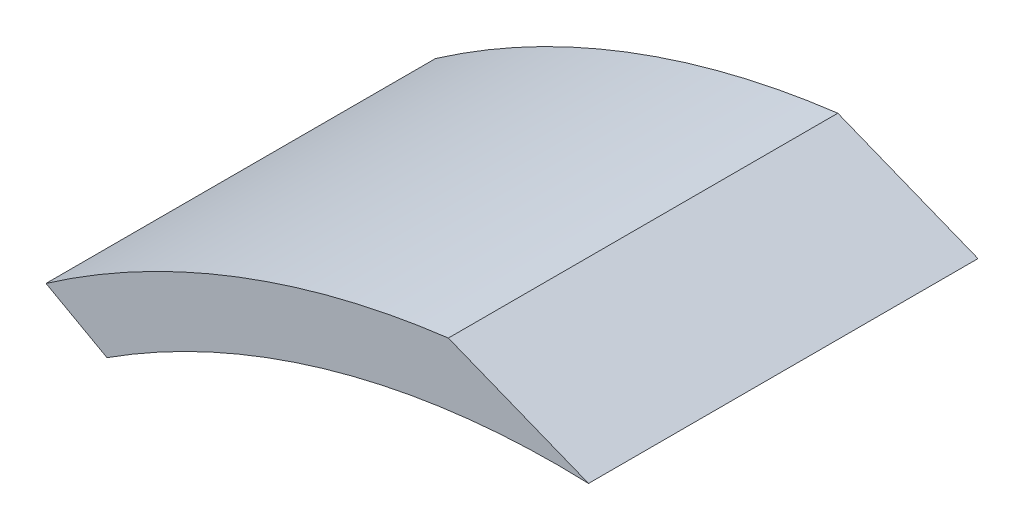
from build123d import *

# Parameters (mm, degrees)
BOSS_EXTRUDE1_DEPTH = 210
CUT_EXTRUDE1_REACH  = 379.535
CUT_EXTRUDE2_REACH  = 377.003


with BuildPart() as part:
    # Sketch1 → Boss-Extrude1 (new body)
    with BuildSketch(Plane.XY):
        with BuildLine():
            Line((0, 0), (0, -33.45))
            ThreePointArc((0, -33.45), (-142.866754092, -51.269235769), (-272.793704391, -113.296827807))
            Line((-272.793704391, -113.296827807), (-292.568960472, -86.318285465))
            ThreePointArc((-292.568960472, -86.318285465), (-153.270771234, -19.479665275), (0, 0))
        make_face()
    extrude(amount=BOSS_EXTRUDE1_DEPTH)

    # Sketch3 → Cut-Extrude1 (cut, up to next)
    with BuildSketch(Plane(origin=(0, 0, 0), x_dir=(-1, 0, 0), z_dir=(0, 0, -1)), mode=Mode.PRIVATE) as cut_extrude1_sk1:
        Polygon((292.568960472, -86.318285465), (255.457097019, -106.893394239), (272.793704391, -113.296827807), align=None)
    cut_extrude1_tool1 = extrude(cut_extrude1_sk1.sketch, amount=-CUT_EXTRUDE1_REACH, mode=Mode.PRIVATE) & part.part
    add(cut_extrude1_tool1.solids().sort_by_distance((-273.606587, -102.169503, 0))[0], mode=Mode.SUBTRACT)

    # Sketch4 → Cut-Extrude2 (cut, up to next)
    with BuildSketch(Plane(origin=(0, 0, 0), x_dir=(-1, 0, 0), z_dir=(0, 0, -1)), mode=Mode.PRIVATE) as cut_extrude2_sk1:
        Polygon((0, -33.45), (84.004446004, 0), (0, 0), align=None)
    cut_extrude2_tool1 = extrude(cut_extrude2_sk1.sketch, amount=-CUT_EXTRUDE2_REACH, mode=Mode.PRIVATE) & part.part
    add(cut_extrude2_tool1.solids().sort_by_distance((-28.001482, -11.15, 0))[0], mode=Mode.SUBTRACT)


with BuildPart() as cut_extrude2_kept_piece:
    # of the separate pieces the step leaves, the one the design keeps (cut_extrude2_pieces_kept)
    add(part.part.solids().sort_by_distance((-292.568960472, -86.318285465, 0))[0])


solid = cut_extrude2_kept_piece.part
